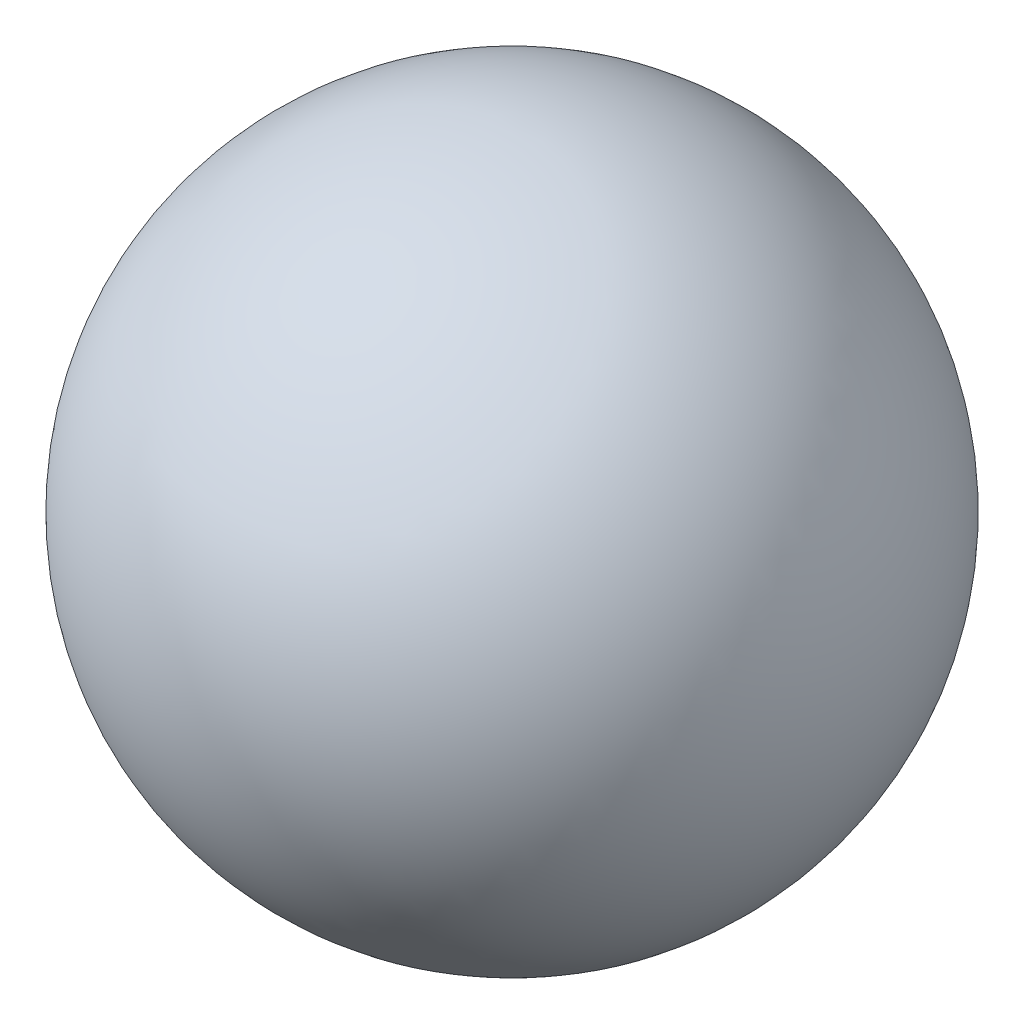
from build123d import *


with BuildPart() as part:
    # Sketch1 → Revolve1 (revolve)
    with BuildSketch(Plane.XY):
        with BuildLine():
            Line((0, 510), (0, -510))
            ThreePointArc((0, -510), (510, 0), (0, 510))
        make_face()
    revolve(axis=Axis((0, 510, 0), (0, -1, 0)))


solid = part.part
